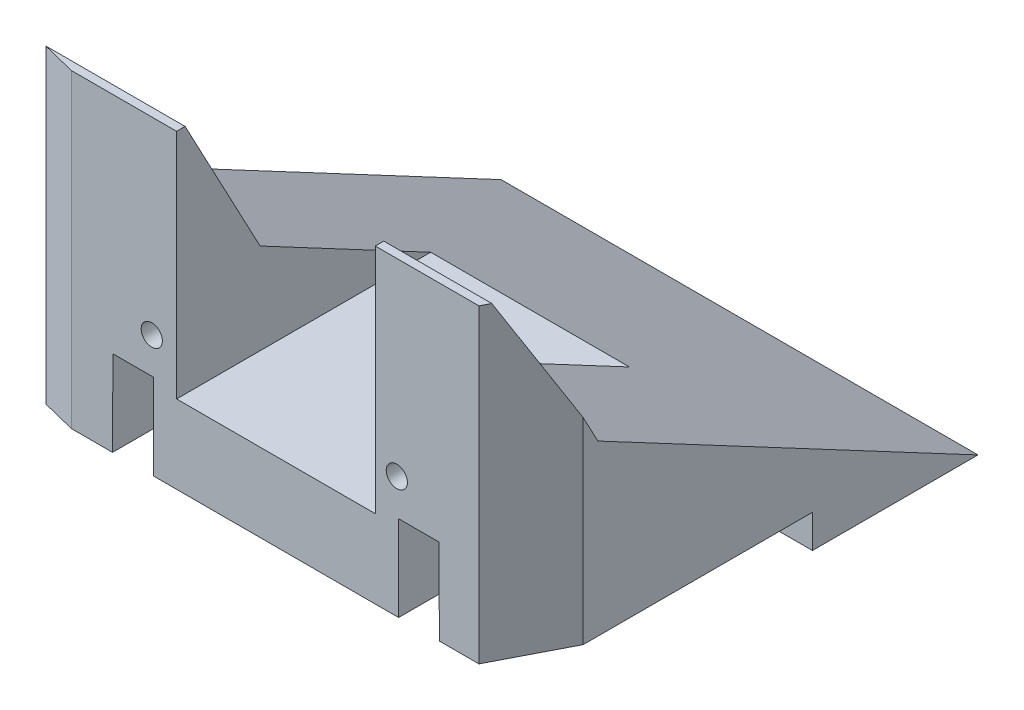
from build123d import *

# Parameters (mm, degrees)
CROQUIS1_W              = 70
CROQUIS1_H              = 51.82
SALIENTE_EXTRUIR1_DEPTH = 72
CORTAR_EXTRUIR1_DEPTH   = 72
CROQUIS5_W              = 30
CROQUIS5_H              = 62
CORTAR_EXTRUIR2_DEPTH   = 35
CORTAR_EXTRUIR3_REACH   = 74
CROQUIS6_W              = 45
CROQUIS6_H              = 5
CORTAR_EXTRUIR4_REACH   = 53.82
CORTAR_EXTRUIR5_REACH   = 53.82
CROQUIS18_R             = 1.6
CORTAR_EXTRUIR7_DEPTH   = 15
CROQUIS19_R             = 1.75
CROQUIS19_R_2           = 2.5
CORTAR_EXTRUIR8_DEPTH   = 6
CORTAR_EXTRUIR10_DEPTH  = 10


with BuildPart() as part:
    # Croquis1 → Saliente-Extruir1 (new body)
    with BuildSketch(Plane(origin=(0, 0, 0), x_dir=(0, 0, -1), z_dir=(1, 0, 0))):
        with Locations((35, 25.91)):
            Rectangle(CROQUIS1_W, CROQUIS1_H)
    extrude(amount=SALIENTE_EXTRUIR1_DEPTH)

    # Croquis4 → Cortar-Extruir1 (cut)
    with BuildSketch(Plane(origin=(72, 0, 0), x_dir=(0, 0, -1), z_dir=(1, 0, 0))):
        Polygon((12.608406464, 30.515651581), (70, 0), (70, 51.82), (1.280683474, 51.82), align=None)
    extrude(amount=-CORTAR_EXTRUIR1_DEPTH, mode=Mode.SUBTRACT)

    # Croquis5 → Cortar-Extruir2 (cut)
    with BuildSketch(Plane(origin=(0, 51.82, 0), x_dir=(1, 0, 0), z_dir=(0, 1, 0))):
        with Locations((36, 31)):
            Rectangle(CROQUIS5_W, CROQUIS5_H)
    extrude(amount=-CORTAR_EXTRUIR2_DEPTH, mode=Mode.SUBTRACT)

    # Croquis6 → Cortar-Extruir3 (cut, up to next)
    with BuildSketch(Plane(origin=(72, 0, 0), x_dir=(0, 0, -1), z_dir=(1, 0, 0)), mode=Mode.PRIVATE) as cortar_extruir3_sk1:
        with Locations((22.5, 2.5)):
            Rectangle(CROQUIS6_W, CROQUIS6_H)
    cortar_extruir3_tool1 = extrude(cortar_extruir3_sk1.sketch, amount=-CORTAR_EXTRUIR3_REACH, mode=Mode.PRIVATE) & part.part
    add(cortar_extruir3_tool1.solids().sort_by_distance((72, 2.5, -22.5))[0], mode=Mode.SUBTRACT)

    # Croquis7 → Cortar-Extruir4 (cut, up to next)
    with BuildSketch(Plane(origin=(0, 51.82, 0), x_dir=(1, 0, 0), z_dir=(0, 1, 0)), mode=Mode.PRIVATE) as cortar_extruir4_sk1:
        Polygon((5.10343226, 0), (0, 1.280683474), (0, 0), align=None)
    cortar_extruir4_tool1 = extrude(cortar_extruir4_sk1.sketch, amount=-CORTAR_EXTRUIR4_REACH, mode=Mode.PRIVATE) & part.part
    add(cortar_extruir4_tool1.solids().sort_by_distance((1.701144, 51.82, -0.426894))[0], mode=Mode.SUBTRACT)

    # Croquis8 → Cortar-Extruir5 (cut, up to next)
    with BuildSketch(Plane(origin=(0, 51.82, 0), x_dir=(1, 0, 0), z_dir=(0, 1, 0)), mode=Mode.PRIVATE) as cortar_extruir5_sk1:
        Polygon((66.648328853, 0), (72, 10.382844773), (72, 0), align=None)
    cortar_extruir5_tool1 = extrude(cortar_extruir5_sk1.sketch, amount=-CORTAR_EXTRUIR5_REACH, mode=Mode.PRIVATE) & part.part
    add(cortar_extruir5_tool1.solids().sort_by_distance((70.21611, 51.82, -3.460948))[0], mode=Mode.SUBTRACT)

    # Croquis18 → Cortar-Extruir7 (cut)
    with BuildSketch(Plane.XY):
        with Locations((17.25, 23.32)):
            Circle(CROQUIS18_R)
        with Locations((54.25, 23.32)):
            Circle(CROQUIS18_R)
    extrude(amount=-CORTAR_EXTRUIR7_DEPTH, mode=Mode.SUBTRACT)

    # Croquis19 → Cortar-Extruir8 (cut)
    with BuildSketch(Plane.XZ.offset(-5)):
        with Locations((10, -35)):
            Circle(CROQUIS19_R)
        with Locations((10, -10)):
            Circle(CROQUIS19_R)
        with Locations((62, -35)):
            Circle(CROQUIS19_R)
        with Locations((62, -10)):
            Circle(CROQUIS19_R)
        with Locations((36, -35)):
            Circle(CROQUIS19_R_2)
        with Locations((36, -10)):
            Circle(CROQUIS19_R_2)
    extrude(amount=-CORTAR_EXTRUIR8_DEPTH, mode=Mode.SUBTRACT)

    # Croquis21 → Cortar-Extruir10 (cut)
    with BuildSketch(Plane.XY):
        Polygon((11.328328853, 5), (17.478328853, 5), (17.478328853, 17.92), (11.378328853, 17.92), align=None)
        Polygon((60.671671147, 5), (54.521671147, 5), (54.521671147, 17.92), (60.621671147, 17.92), align=None)
    extrude(amount=-CORTAR_EXTRUIR10_DEPTH, mode=Mode.SUBTRACT)


solid = part.part
